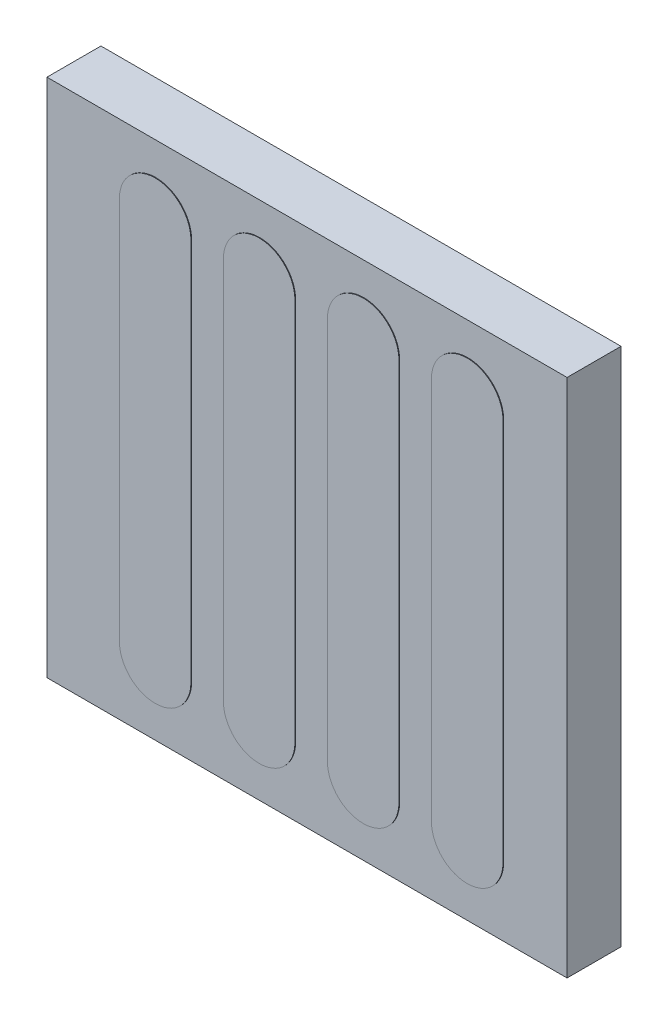
from build123d import *

# Parameters (mm, degrees)
BOSS_EXTRUDE1_DEPTH   = 4.2
BOSS_EXTRUDE1_2_DEPTH = 4.2
BOSS_EXTRUDE1_3_DEPTH = 4.2
BOSS_EXTRUDE1_4_DEPTH = 4.2
SKETCH2_W             = 40
SKETCH2_H             = 40
BOSS_EXTRUDE2_DEPTH   = 4.15


with BuildPart() as part:
    # Sketch1 → Boss-Extrude1 (new body)
    with BuildSketch(Plane.XY):
        with BuildLine():
            Line((9.620275047, 14.75), (9.620275047, -14.75))
            ThreePointArc((9.620275047, -14.75), (12.370275047, -17.5), (15.120275047, -14.75))
            Line((15.120275047, -14.75), (15.120275047, 14.75))
            ThreePointArc((15.120275047, 14.75), (12.370275047, 17.5), (9.620275047, 14.75))
        make_face()
    extrude(amount=BOSS_EXTRUDE1_DEPTH)



with BuildPart() as body_2:
    # Sketch1 → Boss-Extrude1 2 (new body)
    with BuildSketch(Plane.XY):
        with BuildLine():
            Line((-14.379724953, 14.75), (-14.379724953, -14.75))
            ThreePointArc((-14.379724953, -14.75), (-11.629724953, -17.5), (-8.879724953, -14.75))
            Line((-8.879724953, -14.75), (-8.879724953, 14.75))
            ThreePointArc((-8.879724953, 14.75), (-11.629724953, 17.5), (-14.379724953, 14.75))
        make_face()
    extrude(amount=BOSS_EXTRUDE1_2_DEPTH)


with BuildPart() as body_3:
    # Sketch1 → Boss-Extrude1 3 (new body)
    with BuildSketch(Plane.XY):
        with BuildLine():
            ThreePointArc((7.120275047, 14.75), (4.370275047, 17.5), (1.620275047, 14.75))
            Line((1.620275047, 14.75), (1.620275047, -14.75))
            ThreePointArc((1.620275047, -14.75), (4.370275047, -17.5), (7.120275047, -14.75))
            Line((7.120275047, -14.75), (7.120275047, 14.75))
        make_face()
    extrude(amount=BOSS_EXTRUDE1_3_DEPTH)


with BuildPart() as body_4:
    # Sketch1 → Boss-Extrude1 4 (new body)
    with BuildSketch(Plane.XY):
        with BuildLine():
            ThreePointArc((-0.879724953, 14.75), (-3.629724953, 17.5), (-6.379724953, 14.75))
            Line((-6.379724953, 14.75), (-6.379724953, -14.75))
            ThreePointArc((-6.379724953, -14.75), (-3.629724953, -17.5), (-0.879724953, -14.75))
            Line((-0.879724953, -14.75), (-0.879724953, 14.75))
        make_face()
    extrude(amount=BOSS_EXTRUDE1_4_DEPTH)


with BuildPart() as part_1:
    add(part.part)

    add(body_2.part)  # Boss-Extrude2 merges body 2

    add(body_3.part)  # Boss-Extrude2 merges body 3

    add(body_4.part)  # Boss-Extrude2 merges body 4
    # Sketch2 → Boss-Extrude2 (add)
    with BuildSketch(Plane.XY):
        Rectangle(SKETCH2_W, SKETCH2_H)
    extrude(amount=BOSS_EXTRUDE2_DEPTH)


solid = part_1.part
